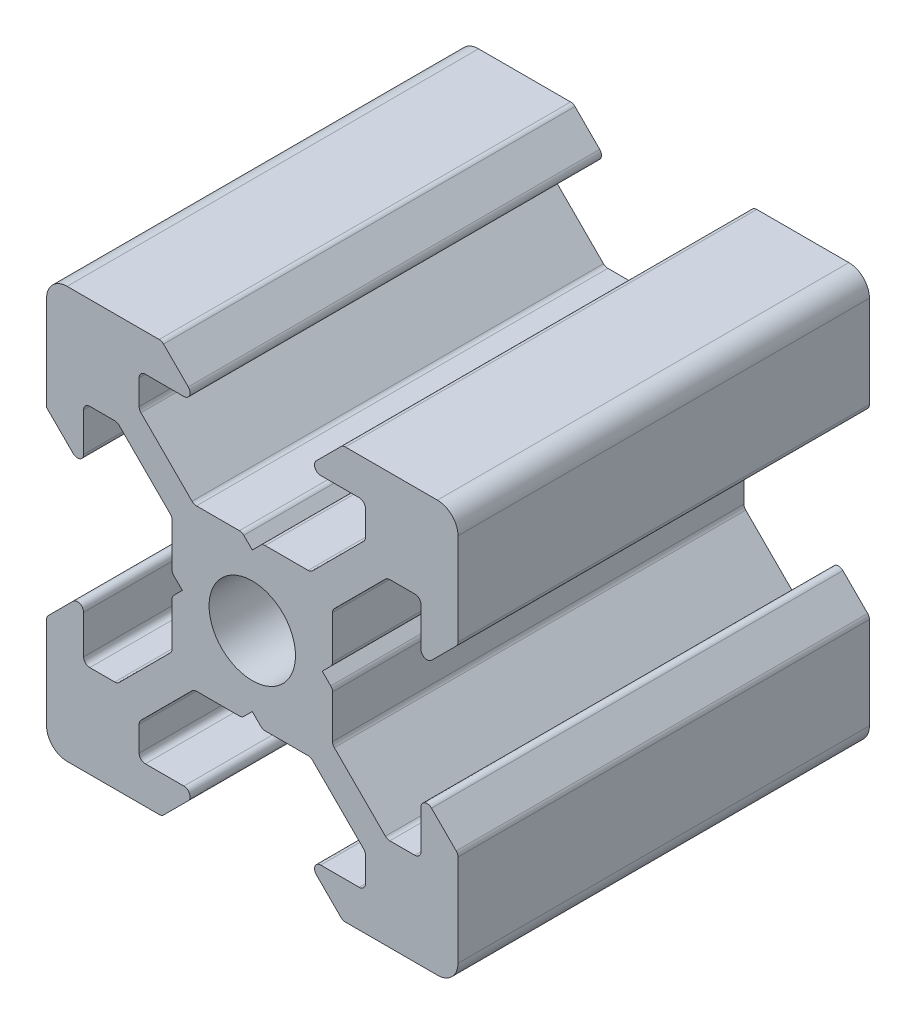
from build123d import *

# Parameters (mm, degrees)
SKETCH_1_R      = 2.1
EXTRUDE_1_DEPTH = 20
FILLET_1_R      = 1
FILLET_2_R      = 0.3


with BuildPart() as part:
    # Эскиз1 → Бобышка-Вытянуть1 (new body)
    with BuildSketch(Plane.XY):
        Polygon((-10, 10), (-4.4, 10), (-2.6, 8.2), (-5.499339828, 8.2), (-5.499339828, 6.56), (-2.84, 3.900660172), (-0.5, 3.900660172), (0, 3.400660172), (0.5, 3.900660172), (2.84, 3.900660172), (5.499339828, 6.56), (5.499339828, 8.2), (2.6, 8.2), (4.4, 10), (10, 10), (10, 4.4), (8.2, 2.6), (8.2, 5.499339828), (6.56, 5.499339828), (3.900660172, 2.84), (3.900660172, 0.5), (3.400660172, 0), (3.900660172, -0.5), (3.900660172, -2.84), (6.56, -5.499339828), (8.2, -5.499339828), (8.2, -2.6), (10, -4.4), (10, -10), (4.4, -10), (2.6, -8.2), (5.499339828, -8.2), (5.499339828, -6.56), (2.84, -3.900660172), (0.5, -3.900660172), (0, -3.400660172), (-0.5, -3.900660172), (-2.84, -3.900660172), (-5.499339828, -6.56), (-5.499339828, -8.2), (-2.6, -8.2), (-4.4, -10), (-10, -10), (-10, -4.4), (-8.2, -2.6), (-8.2, -5.499339828), (-6.56, -5.499339828), (-3.900660172, -2.84), (-3.900660172, -0.5), (-3.400660172, 0), (-3.900660172, 0.5), (-3.900660172, 2.84), (-6.56, 5.499339828), (-8.2, 5.499339828), (-8.2, 2.6), (-10, 4.4), align=None)
        Circle(SKETCH_1_R, mode=Mode.SUBTRACT)
    extrude(amount=EXTRUDE_1_DEPTH)

    # Скругление1
    fillet_1_edges = [part.edges().sort_by_distance(p)[0] for p in [
        (-10, 10, 10),
        (10, 10, 10),
        (10, -10, 10),
        (-10, -10, 10),
    ]]
    fillet(fillet_1_edges, radius=FILLET_1_R)

    # Скругление2
    fillet_2_edges = [part.edges().sort_by_distance(p)[0] for p in [
        (-4.4, 10, 10),
        (-2.6, 8.2, 10),
        (-5.499339828, 8.2, 10),
        (-5.499339828, 6.56, 10),
        (-2.84, 3.900660172, 10),
        (-0.5, 3.900660172, 10),
        (0.5, 3.900660172, 10),
        (2.84, 3.900660172, 10),
        (5.499339828, 6.56, 10),
        (5.499339828, 8.2, 10),
        (2.6, 8.2, 10),
        (4.4, 10, 10),
        (10, 4.4, 10),
        (8.2, 2.6, 10),
        (8.2, 5.499339828, 10),
        (6.56, 5.499339828, 10),
        (3.900660172, 2.84, 10),
        (3.900660172, 0.5, 10),
        (3.900660172, -0.5, 10),
        (3.900660172, -2.84, 10),
        (6.56, -5.499339828, 10),
        (8.2, -5.499339828, 10),
        (8.2, -2.6, 10),
        (10, -4.4, 10),
        (4.4, -10, 10),
        (2.6, -8.2, 10),
        (5.499339828, -8.2, 10),
        (5.499339828, -6.56, 10),
        (2.84, -3.900660172, 10),
        (0.5, -3.900660172, 10),
        (-0.5, -3.900660172, 10),
        (-2.84, -3.900660172, 10),
        (-5.499339828, -6.56, 10),
        (-5.499339828, -8.2, 10),
        (-2.6, -8.2, 10),
        (-4.4, -10, 10),
        (-10, -4.4, 10),
        (-8.2, -2.6, 10),
        (-8.2, -5.499339828, 10),
        (-6.56, -5.499339828, 10),
        (-3.900660172, -2.84, 10),
        (-3.900660172, -0.5, 10),
        (-3.900660172, 0.5, 10),
        (-3.900660172, 2.84, 10),
        (-6.56, 5.499339828, 10),
        (-8.2, 5.499339828, 10),
        (-8.2, 2.6, 10),
    ]]
    fillet(fillet_2_edges, radius=FILLET_2_R)


solid = part.part
